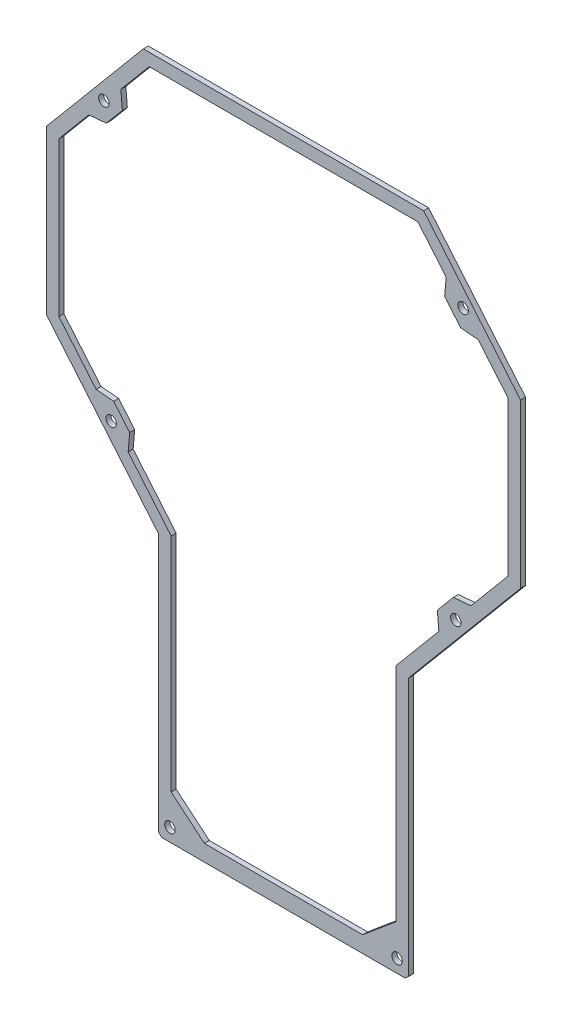
from build123d import *

# Parameters (mm, degrees)
RESSALTO_EXTRUS_O1_DEPTH = 2
CORTE_EXTRUS_O1_REACH    = 4
ESBO_O2_R                = 2.1
CORTE_EXTRUS_O2_DEPTH    = 10


with BuildPart() as part:
    # Esboço1 → Ressalto-extrusão1 (new body)
    with BuildSketch(Plane.XY):
        Polygon((56.463679973, 135.159747673), (-55.864365487, 135.159747673), (-94.700342757, 88.87683224), (-94.700342757, 23.490318666), (-49.700342757, -30.138593001), (-49.700342757, -133.732537696), (-48.380219867, -134.840252327), (48.979534352, -134.840252327), (50.299657243, -133.732537696), (50.299657243, -30.138593001), (95.299657243, 23.490318666), (95.299657243, 88.87683224), align=None)
    extrude(amount=RESSALTO_EXTRUS_O1_DEPTH)

    # Esboço2 → Corte-extrusão1 (cut, up to next)
    with BuildSketch(Plane.XY.offset(2), mode=Mode.PRIVATE) as corte_extrus_o1_sk1:
        with Locations((-71.672714117, 109.298736063)):
            Circle(ESBO_O2_R)
    corte_extrus_o1_tool1 = extrude(corte_extrus_o1_sk1.sketch, amount=-CORTE_EXTRUS_O1_REACH, mode=Mode.PRIVATE) & part.part
    add(corte_extrus_o1_tool1.solids().sort_by_distance((-71.672714, 109.298736, 2))[0], mode=Mode.SUBTRACT)
    # Esboço2 → Corte-extrusão1 (cut, up to next)
    with BuildSketch(Plane.XY.offset(2), mode=Mode.PRIVATE) as corte_extrus_o1_sk2:
        with Locations((-45.200342757, -129.610252327)):
            Circle(ESBO_O2_R)
    corte_extrus_o1_tool2 = extrude(corte_extrus_o1_sk2.sketch, amount=-CORTE_EXTRUS_O1_REACH, mode=Mode.PRIVATE) & part.part
    add(corte_extrus_o1_tool2.solids().sort_by_distance((-45.200343, -129.610252, 2))[0], mode=Mode.SUBTRACT)
    # Esboço2 → Corte-extrusão1 (cut, up to next)
    with BuildSketch(Plane.XY.offset(2), mode=Mode.PRIVATE) as corte_extrus_o1_sk3:
        with Locations((45.799657243, -129.610252327)):
            Circle(ESBO_O2_R)
    corte_extrus_o1_tool3 = extrude(corte_extrus_o1_sk3.sketch, amount=-CORTE_EXTRUS_O1_REACH, mode=Mode.PRIVATE) & part.part
    add(corte_extrus_o1_tool3.solids().sort_by_distance((45.799657, -129.610252, 2))[0], mode=Mode.SUBTRACT)
    # Esboço2 → Corte-extrusão1 (cut, up to next)
    with BuildSketch(Plane.XY.offset(2), mode=Mode.PRIVATE) as corte_extrus_o1_sk4:
        with Locations((72.272028603, 109.298736063)):
            Circle(ESBO_O2_R)
    corte_extrus_o1_tool4 = extrude(corte_extrus_o1_sk4.sketch, amount=-CORTE_EXTRUS_O1_REACH, mode=Mode.PRIVATE) & part.part
    add(corte_extrus_o1_tool4.solids().sort_by_distance((72.272029, 109.298736, 2))[0], mode=Mode.SUBTRACT)
    # Esboço2 → Corte-extrusão1 (cut, up to next)
    with BuildSketch(Plane.XY.offset(2), mode=Mode.PRIVATE) as corte_extrus_o1_sk5:
        with Locations((-68.753142763, -0.431592924)):
            Circle(ESBO_O2_R)
    corte_extrus_o1_tool5 = extrude(corte_extrus_o1_sk5.sketch, amount=-CORTE_EXTRUS_O1_REACH, mode=Mode.PRIVATE) & part.part
    add(corte_extrus_o1_tool5.solids().sort_by_distance((-68.753143, -0.431593, 2))[0], mode=Mode.SUBTRACT)
    # Esboço2 → Corte-extrusão1 (cut, up to next)
    with BuildSketch(Plane.XY.offset(2), mode=Mode.PRIVATE) as corte_extrus_o1_sk6:
        with Locations((69.352457249, -0.431592924)):
            Circle(ESBO_O2_R)
    corte_extrus_o1_tool6 = extrude(corte_extrus_o1_sk6.sketch, amount=-CORTE_EXTRUS_O1_REACH, mode=Mode.PRIVATE) & part.part
    add(corte_extrus_o1_tool6.solids().sort_by_distance((69.352457, -0.431593, 2))[0], mode=Mode.SUBTRACT)

    # Esboço3 → Corte-extrusão2 (cut)
    with BuildSketch(Plane.XY.offset(2)):
        Polygon((-53.532827197, 130.159747673), (-64.879577854, 116.637216813), (-64.263293687, 109.593056549), (-70.675930858, 101.950773162), (-77.720091122, 101.334488995), (-89.700342757, 87.056981069), (-89.700342757, 25.310169837), (-74.789956765, 7.540663764), (-67.745796501, 6.924379597), (-61.334000151, -0.716901738), (-61.950284318, -7.761062002), (-44.700342757, -28.318741829), (-44.700342757, -117.173246706), (-31.407709232, -128.327090595), (32.007023717, -128.327090595), (45.299657243, -117.173246706), (45.299657243, -28.318741829), (62.549598803, -7.761062002), (61.933314636, -0.716901738), (68.345110987, 6.924379597), (75.389271251, 7.540663764), (90.299657243, 25.310169837), (90.299657243, 87.056981069), (78.319405608, 101.334488995), (71.275245343, 101.950773162), (64.862608173, 109.593056549), (65.47889234, 116.637216813), (54.132141682, 130.159747673), align=None)
    extrude(amount=-CORTE_EXTRUS_O2_DEPTH, mode=Mode.SUBTRACT)


solid = part.part
